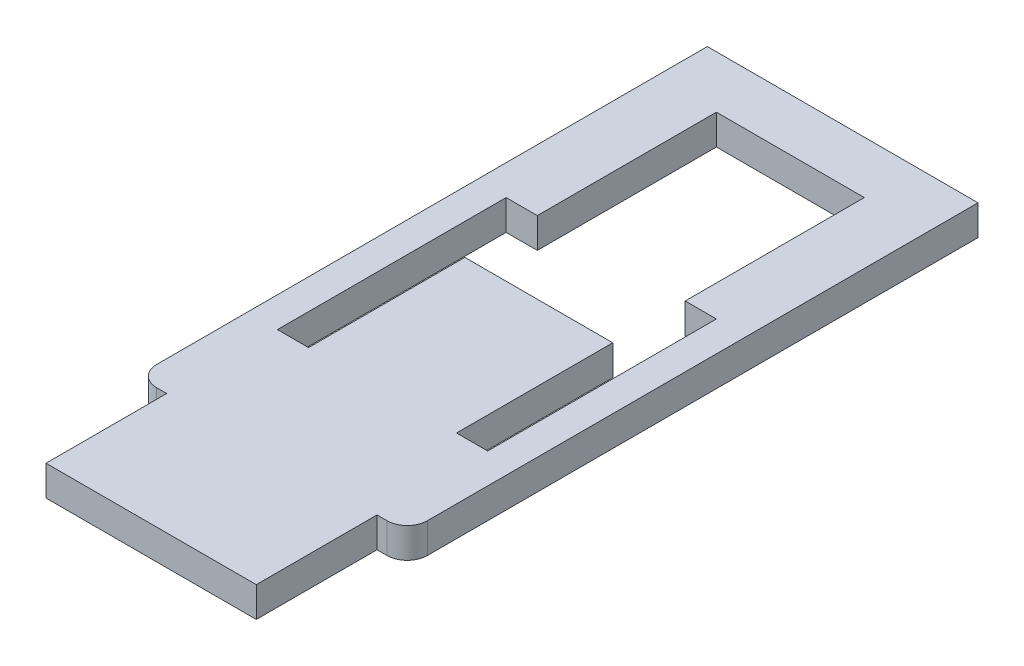
from build123d import *

# Parameters (mm, degrees)
BOSS_EXTRUDE1_DEPTH = 3
FILLET1_R           = 2


with BuildPart() as part:
    # Sketch1 → Boss-Extrude1 (new body)
    with BuildSketch(Plane(origin=(0, 0, 0), x_dir=(1, 0, 0), z_dir=(0, 1, 0))):
        Polygon((-10.45025, -22.36565), (-10.45025, -34.36565), (10.45025, -34.36565), (10.45025, -22.36565), (13.45025, -22.36565), (13.45025, 34.36565), (-13.45025, 34.36565), (-13.45025, -22.36565), align=None)
        Polygon((-7.35025, -11.36565), (-10.45025, -11.36565), (-10.45025, 11.36565), (-7.35025, 11.36565), (-7.35025, 29.16565), (7.35025, 29.16565), (7.35025, 11.36565), (10.45025, 11.36565), (10.45025, -11.36565), (7.35025, -11.36565), (7.35025, 4.16565), (-7.35025, 4.16565), align=None, mode=Mode.SUBTRACT)
    extrude(amount=BOSS_EXTRUDE1_DEPTH)

    # Fillet1
    fillet1_edges = [part.edges().sort_by_distance(p)[0] for p in [
        (-13.45025, 1.5, 22.36565),
        (13.45025, 1.5, 22.36565),
    ]]
    fillet(fillet1_edges, radius=FILLET1_R)


solid = part.part
